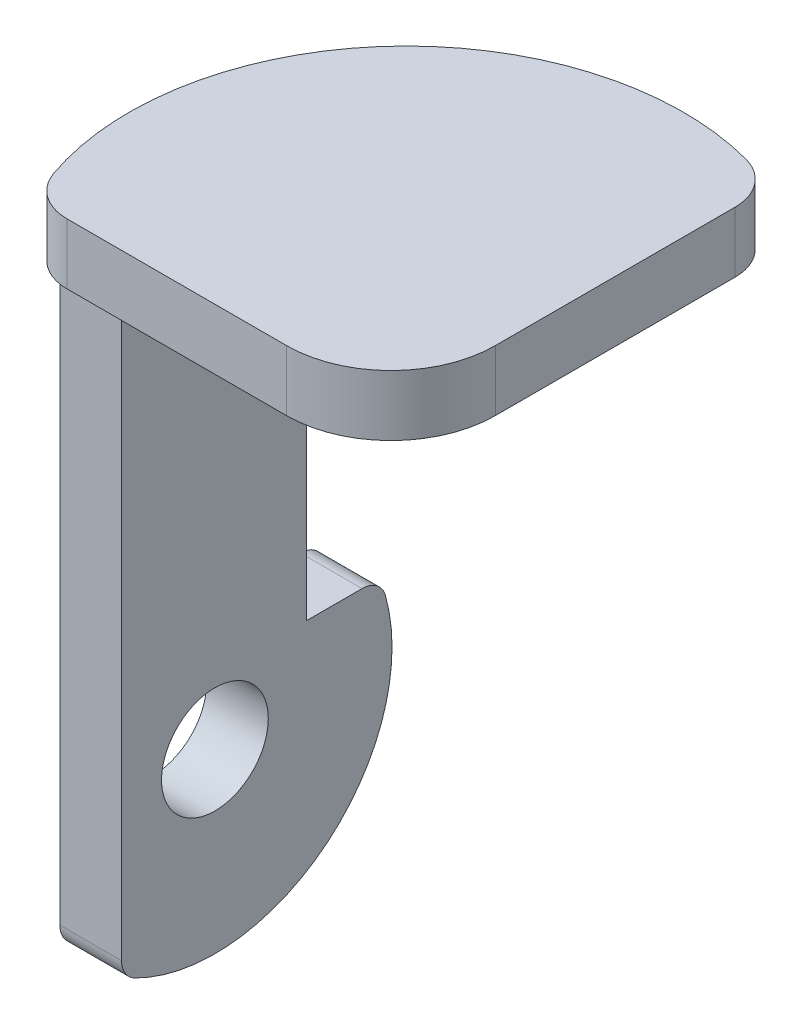
from build123d import *

# Parameters (mm, degrees)
BOSS_EXTRUDE2_DEPTH = 25
SKETCH2_R           = 22
BOSS_EXTRUDE5_DEPTH = 25.4


with BuildPart() as part:
    # Sketch1 → Boss-Extrude2 (new body)
    with BuildSketch(Plane(origin=(0, 0, 0), x_dir=(1, 0, 0), z_dir=(0, 1, 0))):
        with BuildLine():
            Line((44.45, 62.775174993), (44.45, -36.1))
            ThreePointArc((44.45, -36.1), (31.855591591, -66.505591591), (1.45, -79.1))
            Line((1.45, -79.1), (-89.128278341, -79.1))
            ThreePointArc((-89.128278341, -79.1), (-100.73330157, -75.38875182), (-108.031412665, -65.632343584))
            ThreePointArc((-108.031412665, -65.632343584), (-83.618418377, 49.62592706), (29.635577943, 82.091224832))
            ThreePointArc((29.635577943, 82.091224832), (40.319964695, 74.946626039), (44.45, 62.775174993))
        make_face()
    extrude(amount=-BOSS_EXTRUDE2_DEPTH)


with BuildPart() as body_2:
    # Sketch2 → Boss-Extrude5 (new body)
    with BuildSketch(Plane(origin=(-110, 0, 0), x_dir=(0, 0, -1), z_dir=(1, 0, 0))):
        with BuildLine():
            Line((-61.1, -215.369552032), (-61.1, -271.554514433))
            ThreePointArc((-61.1, -271.554514433), (-59.621681032, -276.787195618), (-55.623809524, -280.472762433))
            ThreePointArc((-55.623809524, -280.472762433), (23.738762296, -271.776281319), (47.675282365, -195.611397044))
            ThreePointArc((47.675282365, -195.611397044), (44.087324044, -190.347235632), (38.048531356, -188.317993618))
            Line((38.048531356, -188.317993618), (15.1, -188.317993618))
            Line((15.1, -188.317993618), (15.1, -25.369552032))
            Line((15.1, -25.369552032), (-61.1, -25.369552032))
            Line((-61.1, -25.369552032), (-61.1, -215.369552032))
        make_face()
        with Locations((-22.6, -215.369552032)):
            Circle(SKETCH2_R, mode=Mode.SUBTRACT)
    extrude(amount=BOSS_EXTRUDE5_DEPTH)


solid = Compound([part.part, body_2.part])
